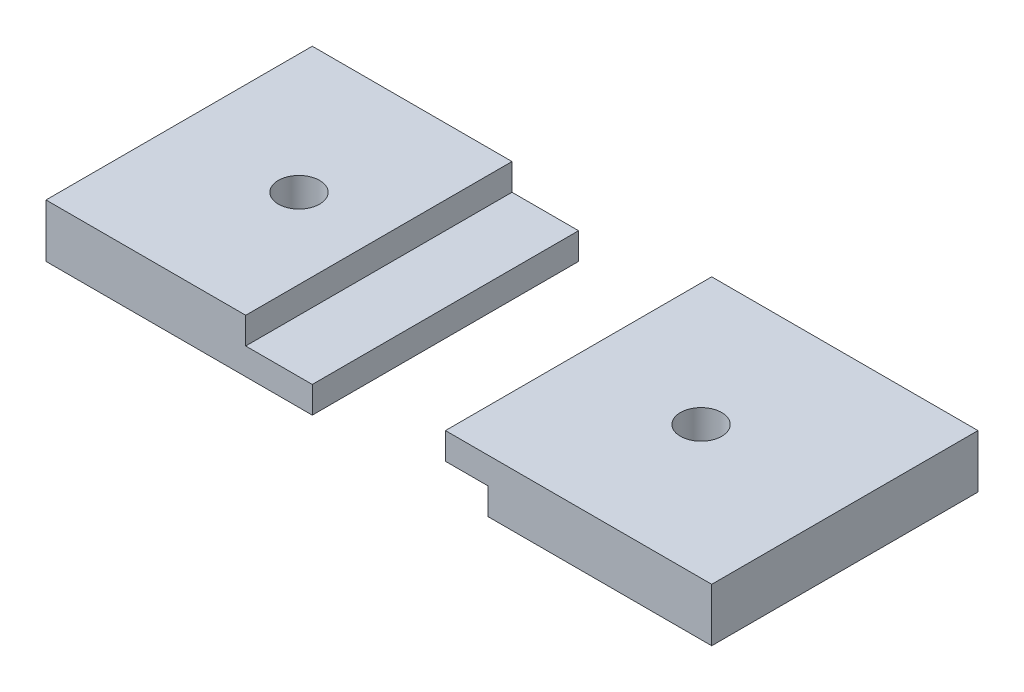
from build123d import *

# Parameters (mm, degrees)
SKETCH1_W             = 20
SKETCH1_H             = 20
BOSS_EXTRUDE1_DEPTH   = 4
BOSS_EXTRUDE1_2_DEPTH = 4
SKETCH2_W             = 20
SKETCH2_H             = 2
CUT_EXTRUDE1_DEPTH    = 5
SKETCH3_W             = 20
SKETCH3_H             = 2
CUT_EXTRUDE2_DEPTH    = 3.2
SKETCH5_R             = 1.55
CUT_EXTRUDE3_DEPTH    = 4
SKETCH6_R             = 1.55
CUT_EXTRUDE4_DEPTH    = 4


with BuildPart() as part:
    # Sketch1 → Boss-Extrude1 (new body)
    with BuildSketch(Plane(origin=(0, 0, 0), x_dir=(1, 0, 0), z_dir=(0, 1, 0))):
        with Locations((-10, 10)):
            Rectangle(SKETCH1_W, SKETCH1_H)
    extrude(amount=BOSS_EXTRUDE1_DEPTH)

    # Sketch2 → Cut-Extrude1 (cut)
    with BuildSketch(Plane(origin=(0, 0, 0), x_dir=(0, 0, -1), z_dir=(1, 0, 0))):
        with Locations((10, 3)):
            Rectangle(SKETCH2_W, SKETCH2_H)
    extrude(amount=-CUT_EXTRUDE1_DEPTH, mode=Mode.SUBTRACT)

    # Sketch5 → Cut-Extrude3 (cut)
    with BuildSketch(Plane(origin=(0, 4, 0), x_dir=(1, 0, 0), z_dir=(0, 1, 0))):
        with Locations((-11, 10)):
            Circle(SKETCH5_R)
    extrude(amount=-CUT_EXTRUDE3_DEPTH, mode=Mode.SUBTRACT)


with BuildPart() as body_2:
    # Sketch1 → Boss-Extrude1 2 (new body)
    with BuildSketch(Plane(origin=(0, 0, 0), x_dir=(1, 0, 0), z_dir=(0, 1, 0))):
        with Locations((20, 10)):
            Rectangle(SKETCH1_W, SKETCH1_H)
    extrude(amount=BOSS_EXTRUDE1_2_DEPTH)

    # Sketch3 → Cut-Extrude2 (cut)
    with BuildSketch(Plane.ZY.offset(-10)):
        with Locations((-10, 1)):
            Rectangle(SKETCH3_W, SKETCH3_H)
    extrude(amount=-CUT_EXTRUDE2_DEPTH, mode=Mode.SUBTRACT)

    # Sketch6 → Cut-Extrude4 (cut)
    with BuildSketch(Plane(origin=(0, 4, 0), x_dir=(1, 0, 0), z_dir=(0, 1, 0))):
        with Locations((19.2, 10)):
            Circle(SKETCH6_R)
    extrude(amount=-CUT_EXTRUDE4_DEPTH, mode=Mode.SUBTRACT)


solid = Compound([part.part, body_2.part])
